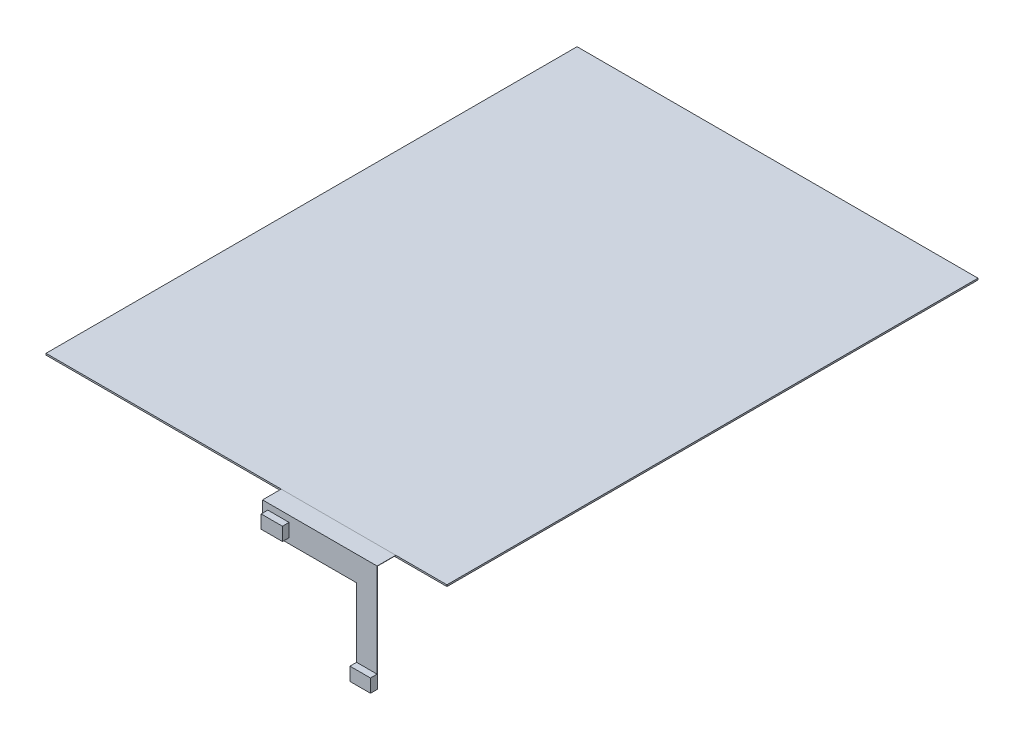
from build123d import *

# Parameters (mm, degrees)
CROQUIS1_W              = 151
CROQUIS1_H              = 200
SALIENTE_EXTRUIR1_DEPTH = 0.6
CROQUIS4_W              = 43.149370068
CROQUIS4_H              = 7.03827607
SALIENTE_EXTRUIR2_DEPTH = 0.1
SALIENTE_EXTRUIR3_DEPTH = 0.1
CROQUIS7_W              = 7.726087965
CROQUIS7_H              = 5
CROQUIS7_W_2            = 8
SALIENTE_EXTRUIR5_DEPTH = 2.5


with BuildPart() as part:
    # Croquis1 → Saliente-Extruir1 (new body)
    with BuildSketch(Plane(origin=(0, 0, 0), x_dir=(1, 0, 0), z_dir=(0, 1, 0))):
        Rectangle(CROQUIS1_W, CROQUIS1_H)
    extrude(amount=SALIENTE_EXTRUIR1_DEPTH)


with BuildPart() as body_2:
    # Croquis4 → Saliente-Extruir2 (new body)
    with BuildSketch(Plane(origin=(0, 0.6, 0), x_dir=(1, 0, 0), z_dir=(0, 1, 0))):
        with Locations((34.65868757, -103.519138035)):
            Rectangle(CROQUIS4_W, CROQUIS4_H)
    extrude(amount=-SALIENTE_EXTRUIR2_DEPTH)

    # Croquis5 → Saliente-Extruir3 (add)
    with BuildSketch(Plane.XY.offset(107.03827607)):
        Polygon((56.233372604, 0.5), (56.233372604, -39.664836745), (48.507284639, -39.664836745), (48.507284639, -8.740162196), (13.084002536, -8.740162196), (13.084002536, 0.5), align=None)
    extrude(amount=-SALIENTE_EXTRUIR3_DEPTH)

    # Croquis7 → Saliente-Extruir5 (add)
    with BuildSketch(Plane.XY.offset(107.03827607)):
        with Locations((52.370328622, -37.164836745)):
            Rectangle(CROQUIS7_W, CROQUIS7_H)
        with Locations((19.084002536, -4.240162196)):
            Rectangle(CROQUIS7_W_2, CROQUIS7_H)
    extrude(amount=SALIENTE_EXTRUIR5_DEPTH)


solid = Compound([part.part, body_2.part])
